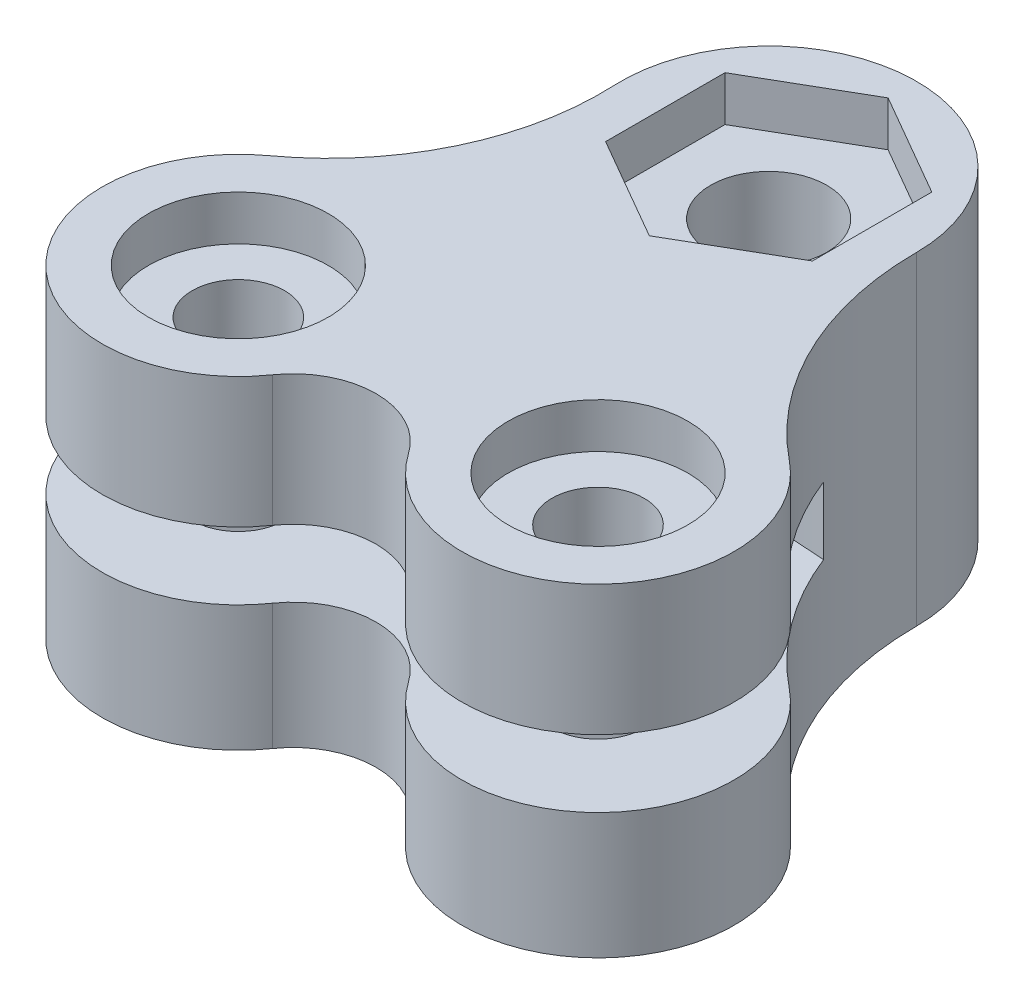
from build123d import *

# Parameters (mm, degrees)
SKETCH1_R           = 3.2639
SKETCH1_R_2         = 4.1021
BOSS_EXTRUDE1_DEPTH = 22.86
CUT_EXTRUDE1_DEPTH  = 4.7625
SKETCH3_R           = 8.1915
BOTTOM_CUTS_DEPTH   = 6.096
SKETCH4_R           = 6.35
TOP_CUTS_DEPTH      = 3.175


with BuildPart() as part:
    # Sketch1 → Boss-Extrude1 (new body)
    with BuildSketch(Plane(origin=(0, 0, 0), x_dir=(1, 0, 0), z_dir=(0, 1, 0))):
        with BuildLine():
            ThreePointArc((-10.440306098, 157.003610008), (-12.313301142, 147.763224627), (-18.350908637, 140.521668981))
            ThreePointArc((-18.350908637, 140.521668981), (-19.427506678, 125.875984036), (-4.807172888, 127.254748239))
            ThreePointArc((-4.807172888, 127.254748239), (0, 129.766974532), (4.807172888, 127.254748239))
            ThreePointArc((4.807172888, 127.254748239), (19.257850316, 125.71380556), (18.723788674, 140.236593192))
            ThreePointArc((18.723788674, 140.236593192), (12.626773217, 147.928609691), (10.4521, 157.49999996))
            ThreePointArc((10.4521, 157.49999996), (-0.24826502, 167.949151069), (-10.440306098, 157.003610008))
        make_face()
        with Locations((-12.7, 132.743860498)):
            Circle(SKETCH1_R, mode=Mode.SUBTRACT)
        with Locations((12.7, 132.743860498)):
            Circle(SKETCH1_R, mode=Mode.SUBTRACT)
        with Locations((0, 157.49999996)):
            Circle(SKETCH1_R_2, mode=Mode.SUBTRACT)
    extrude(amount=BOSS_EXTRUDE1_DEPTH)

    # Sketch2 → Cut-Extrude1 (cut)
    with BuildSketch(Plane(origin=(0, 8.89, 0), x_dir=(-1, 0, 0), z_dir=(0, -1, 0))):
        with BuildLine():
            ThreePointArc((-18.723788674, 140.236593192), (-19.257850316, 125.71380556), (-4.807172888, 127.254748239))
            ThreePointArc((-4.807172888, 127.254748239), (0, 129.766974532), (4.807172888, 127.254748239))
            ThreePointArc((4.807172888, 127.254748239), (19.427506678, 125.875984036), (18.350908637, 140.521668981))
            ThreePointArc((18.350908637, 140.521668981), (14.325271112, 144.466825655), (11.615435011, 149.40917398))
            ThreePointArc((11.615435011, 149.40917398), (-0.19007082, 149.859879464), (-11.994395391, 149.379229076))
            ThreePointArc((-11.994395391, 149.379229076), (-14.763447186, 144.369489602), (-18.723788674, 140.236593192))
        make_face()
    extrude(amount=-CUT_EXTRUDE1_DEPTH, mode=Mode.SUBTRACT)

    # Sketch3 → bottom-cuts (cut)
    with BuildSketch(Plane.XZ):
        with Locations((0, -157.49999996)):
            Circle(SKETCH3_R)
        Polygon((-18.57375, -129.352649355), (-18.57375, -136.135071642), (-12.7, -139.526282786), (-6.82625, -136.135071642), (-6.82625, -129.352649355), (-12.7, -125.961438211), align=None)
        Polygon((12.7, -125.961438211), (18.57375, -129.352649355), (18.57375, -136.135071642), (12.7, -139.526282786), (6.82625, -136.135071642), (6.82625, -129.352649355), align=None)
    extrude(amount=-BOTTOM_CUTS_DEPTH, mode=Mode.SUBTRACT)

    # Sketch4 → top-cuts (cut)
    with BuildSketch(Plane(origin=(0, 22.86, 0), x_dir=(1, 0, 0), z_dir=(0, 1, 0))):
        with Locations((-12.7, 132.743860498)):
            Circle(SKETCH4_R)
        with Locations((12.7, 132.743860498)):
            Circle(SKETCH4_R)
        Polygon((7.3025, 161.716100301), (0, 165.932200642), (-7.3025, 161.716100301), (-7.3025, 153.283899619), (0, 149.067799278), (7.3025, 153.283899619), align=None)
    extrude(amount=-TOP_CUTS_DEPTH, mode=Mode.SUBTRACT)


solid = part.part
